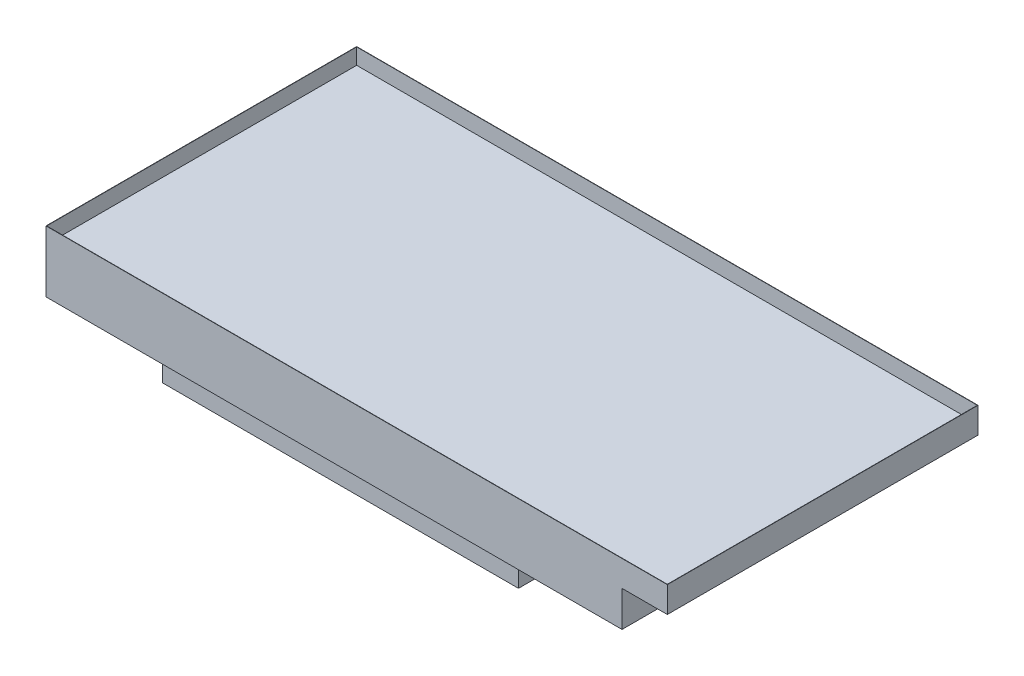
from build123d import *

# Parameters (mm, degrees)
BOSS_EXTRUDE1_DEPTH = 2438.4
SKETCH4_W           = 457.2
SKETCH4_H           = 584.2
CUT_EXTRUDE1_DEPTH  = 3810
SHELL1_T            = -2.54
SKETCH3_W           = 4871.72
SKETCH3_H           = 2433.32
BOSS_EXTRUDE3_DEPTH = 1.778


with BuildPart() as part:
    # Sketch1 → Boss-Extrude1 (new body)
    with BuildSketch(Plane.XY):
        Polygon((-1376.91627907, 1090.13255814), (3499.88372093, 1090.13255814), (3499.88372093, 886.93255814), (3144.28372093, 886.93255814), (3144.28372093, 607.53255814), (2229.88372093, 607.53255814), (2229.88372093, 328.13255814), (1874.28372093, 328.13255814), (1874.28372093, 23.33255814), (-919.71627907, 23.33255814), (-919.71627907, 607.53255814), (-1376.91627907, 607.53255814), align=None)
    extrude(amount=-BOSS_EXTRUDE1_DEPTH)

    # Sketch4 → Cut-Extrude1 (cut)
    with BuildSketch(Plane.ZY.offset(919.71627907)):
        with Locations((-228.6, 315.43255814)):
            Rectangle(SKETCH4_W, SKETCH4_H)
    extrude(amount=-CUT_EXTRUDE1_DEPTH, mode=Mode.SUBTRACT)

    # Shell1
    shell1_openings = [part.faces().sort_by_distance(p)[0] for p in [
        (1061.48372093, 1090.13255814, -1219.2),
    ]]
    offset(amount=SHELL1_T, openings=shell1_openings, kind=Kind.INTERSECTION)

    # Sketch3 → Boss-Extrude3 (add)
    with BuildSketch(Plane(origin=(0, 963.13255814, 0), x_dir=(1, 0, 0), z_dir=(0, 1, 0))):
        with Locations((1061.48372093, 1219.2)):
            Rectangle(SKETCH3_W, SKETCH3_H)
    extrude(amount=BOSS_EXTRUDE3_DEPTH)


solid = part.part
